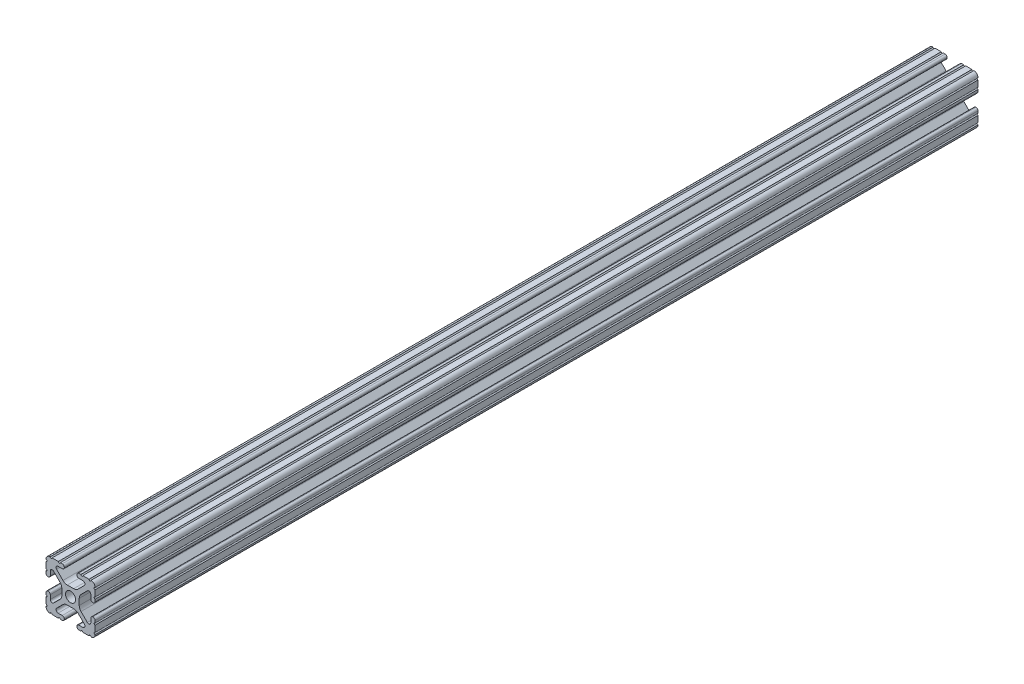
from build123d import *

# Parameters (mm, degrees)
SKETCH1_R           = 2.6035
BOSS_EXTRUDE1_DEPTH = 228.6


with BuildPart() as part:
    # Sketch1 → Boss-Extrude1 (new body, symmetric)
    with BuildSketch(Plane.XY):
        with BuildLine():
            Line((-7.179650497, -8.645192506), (-3.952270251, -5.423690499))
            ThreePointArc((-3.952270251, -5.423690499), (-2.922936451, -4.736929036), (-1.709253557, -4.4958))
            Line((-1.709253557, -4.4958), (1.709253557, -4.4958))
            ThreePointArc((1.709253557, -4.4958), (2.922936451, -4.736929036), (3.952270251, -5.423690499))
            Line((3.952270251, -5.423690499), (7.179650497, -8.645192506))
            ThreePointArc((7.179650497, -8.645192506), (7.41473083, -9.822813117), (6.416408329, -10.4902))
            Line((6.416408329, -10.4902), (4.287512407, -10.4902))
            ThreePointArc((4.287512407, -10.4902), (3.54574862, -10.79744862), (3.2385, -11.539212407))
            Line((3.2385, -11.539212407), (3.2385, -11.650987593))
            ThreePointArc((3.2385, -11.650987593), (3.54574862, -12.39275138), (4.287512407, -12.7))
            Line((4.287512407, -12.7), (5.317126718, -12.7))
            ThreePointArc((5.317126718, -12.7), (5.825126718, -12.192), (6.333126718, -12.7))
            Line((6.333126718, -12.7), (9.550443118, -12.7))
            ThreePointArc((9.550443118, -12.7), (10.058366869, -12.192000006), (10.566443095, -12.699847501))
            ThreePointArc((10.566443095, -12.699847501), (12.082537762, -12.08250727), (12.699846982, -10.566399977))
            ThreePointArc((12.699846982, -10.566399977), (12.192000006, -10.058323491), (12.7, -9.5504))
            Line((12.7, -9.5504), (12.7, -6.3330836))
            ThreePointArc((12.7, -6.3330836), (12.192, -5.8250836), (12.7, -5.3170836))
            Line((12.7, -5.3170836), (12.7, -4.287469289))
            ThreePointArc((12.7, -4.287469289), (12.39275138, -3.545705502), (11.650987593, -3.238456882))
            Line((11.650987593, -3.238456882), (11.539212407, -3.238456882))
            ThreePointArc((11.539212407, -3.238456882), (10.79744862, -3.545705502), (10.4902, -4.287469289))
            Line((10.4902, -4.287469289), (10.4902, -6.402089023))
            ThreePointArc((10.4902, -6.402089023), (9.856505071, -7.351067942), (8.737131347, -7.129408934))
            Line((8.737131347, -7.129408934), (5.441005833, -3.840816462))
            ThreePointArc((5.441005833, -3.840816462), (4.750877967, -2.809883091), (4.5085, -1.593185507))
            Line((4.5085, -1.593185507), (4.5085, 1.593185507))
            ThreePointArc((4.5085, 1.593185507), (4.750877967, 2.809883091), (5.441005833, 3.840816462))
            Line((5.441005833, 3.840816462), (8.737131347, 7.129408934))
            ThreePointArc((8.737131347, 7.129408934), (9.856505071, 7.351067942), (10.4902, 6.402089023))
            Line((10.4902, 6.402089023), (10.4902, 4.287469289))
            ThreePointArc((10.4902, 4.287469289), (10.79744862, 3.545705502), (11.539212407, 3.238456882))
            Line((11.539212407, 3.238456882), (11.650987593, 3.238456882))
            ThreePointArc((11.650987593, 3.238456882), (12.39275138, 3.545705502), (12.7, 4.287469289))
            Line((12.7, 4.287469289), (12.7, 5.3170836))
            ThreePointArc((12.7, 5.3170836), (12.192, 5.8250836), (12.7, 6.3330836))
            Line((12.7, 6.3330836), (12.7, 9.5504))
            ThreePointArc((12.7, 9.5504), (12.192000006, 10.058323491), (12.699846982, 10.566399977))
            ThreePointArc((12.699846982, 10.566399977), (12.082537762, 12.08250727), (10.566443095, 12.699847501))
            ThreePointArc((10.566443095, 12.699847501), (10.058366869, 12.192000006), (9.550443118, 12.7))
            Line((9.550443118, 12.7), (6.333126718, 12.7))
            ThreePointArc((6.333126718, 12.7), (5.825126718, 12.192), (5.317126718, 12.7))
            Line((5.317126718, 12.7), (4.287512407, 12.7))
            ThreePointArc((4.287512407, 12.7), (3.54574862, 12.39275138), (3.2385, 11.650987593))
            Line((3.2385, 11.650987593), (3.2385, 11.539212407))
            ThreePointArc((3.2385, 11.539212407), (3.54574862, 10.79744862), (4.287512407, 10.4902))
            Line((4.287512407, 10.4902), (6.476788598, 10.4902))
            ThreePointArc((6.476788598, 10.4902), (7.432222385, 9.85140422), (7.207036008, 8.724370562))
            Line((7.207036008, 8.724370562), (3.898272566, 5.423169045))
            ThreePointArc((3.898272566, 5.423169045), (2.869120213, 4.736787962), (1.655778399, 4.4958))
            Line((1.655778399, 4.4958), (-1.655778399, 4.4958))
            ThreePointArc((-1.655778399, 4.4958), (-2.869120213, 4.736787962), (-3.898272566, 5.423169045))
            Line((-3.898272566, 5.423169045), (-7.207036008, 8.724370562))
            ThreePointArc((-7.207036008, 8.724370562), (-7.432222385, 9.85140422), (-6.476788598, 10.4902))
            Line((-6.476788598, 10.4902), (-4.287512407, 10.4902))
            ThreePointArc((-4.287512407, 10.4902), (-3.54574862, 10.79744862), (-3.2385, 11.539212407))
            Line((-3.2385, 11.539212407), (-3.2385, 11.650987593))
            ThreePointArc((-3.2385, 11.650987593), (-3.54574862, 12.39275138), (-4.287512407, 12.7))
            Line((-4.287512407, 12.7), (-5.317126718, 12.7))
            ThreePointArc((-5.317126718, 12.7), (-5.825126718, 12.192), (-6.333126718, 12.7))
            Line((-6.333126718, 12.7), (-9.550443118, 12.7))
            ThreePointArc((-9.550443118, 12.7), (-10.058366869, 12.192000006), (-10.566443095, 12.699847501))
            ThreePointArc((-10.566443095, 12.699847501), (-12.082537762, 12.08250727), (-12.699846982, 10.566399977))
            ThreePointArc((-12.699846982, 10.566399977), (-12.192000006, 10.058323491), (-12.7, 9.5504))
            Line((-12.7, 9.5504), (-12.7, 6.3330836))
            ThreePointArc((-12.7, 6.3330836), (-12.192, 5.8250836), (-12.7, 5.3170836))
            Line((-12.7, 5.3170836), (-12.7, 4.287469289))
            ThreePointArc((-12.7, 4.287469289), (-12.39275138, 3.545705502), (-11.650987593, 3.238456882))
            Line((-11.650987593, 3.238456882), (-11.539212407, 3.238456882))
            ThreePointArc((-11.539212407, 3.238456882), (-10.79744862, 3.545705502), (-10.4902, 4.287469289))
            Line((-10.4902, 4.287469289), (-10.4902, 6.402089023))
            ThreePointArc((-10.4902, 6.402089023), (-9.856505071, 7.351067942), (-8.737131347, 7.129408934))
            Line((-8.737131347, 7.129408934), (-5.441005833, 3.840816462))
            ThreePointArc((-5.441005833, 3.840816462), (-4.750877967, 2.809883091), (-4.5085, 1.593185507))
            Line((-4.5085, 1.593185507), (-4.5085, -1.593185507))
            ThreePointArc((-4.5085, -1.593185507), (-4.750877967, -2.809883091), (-5.441005833, -3.840816462))
            Line((-5.441005833, -3.840816462), (-8.737131347, -7.129408934))
            ThreePointArc((-8.737131347, -7.129408934), (-9.856505071, -7.351067942), (-10.4902, -6.402089023))
            Line((-10.4902, -6.402089023), (-10.4902, -4.287469289))
            ThreePointArc((-10.4902, -4.287469289), (-10.79744862, -3.545705502), (-11.539212407, -3.238456882))
            Line((-11.539212407, -3.238456882), (-11.650987593, -3.238456882))
            ThreePointArc((-11.650987593, -3.238456882), (-12.39275138, -3.545705502), (-12.7, -4.287469289))
            Line((-12.7, -4.287469289), (-12.7, -5.3170836))
            ThreePointArc((-12.7, -5.3170836), (-12.192, -5.8250836), (-12.7, -6.3330836))
            Line((-12.7, -6.3330836), (-12.7, -9.5504))
            ThreePointArc((-12.7, -9.5504), (-12.192000006, -10.058323491), (-12.699846982, -10.566399977))
            ThreePointArc((-12.699846982, -10.566399977), (-12.082537762, -12.08250727), (-10.566443095, -12.699847501))
            ThreePointArc((-10.566443095, -12.699847501), (-10.058366869, -12.192000006), (-9.550443118, -12.7))
            Line((-9.550443118, -12.7), (-6.333126718, -12.7))
            ThreePointArc((-6.333126718, -12.7), (-5.825126718, -12.192), (-5.317126718, -12.7))
            Line((-5.317126718, -12.7), (-4.287512407, -12.7))
            ThreePointArc((-4.287512407, -12.7), (-3.54574862, -12.39275138), (-3.2385, -11.650987593))
            Line((-3.2385, -11.650987593), (-3.2385, -11.539212407))
            ThreePointArc((-3.2385, -11.539212407), (-3.54574862, -10.79744862), (-4.287512407, -10.4902))
            Line((-4.287512407, -10.4902), (-6.416408329, -10.4902))
            ThreePointArc((-6.416408329, -10.4902), (-7.41473083, -9.822813117), (-7.179650497, -8.645192506))
        make_face()
        Circle(SKETCH1_R, mode=Mode.SUBTRACT)
    extrude(amount=BOSS_EXTRUDE1_DEPTH, both=True)


solid = part.part
